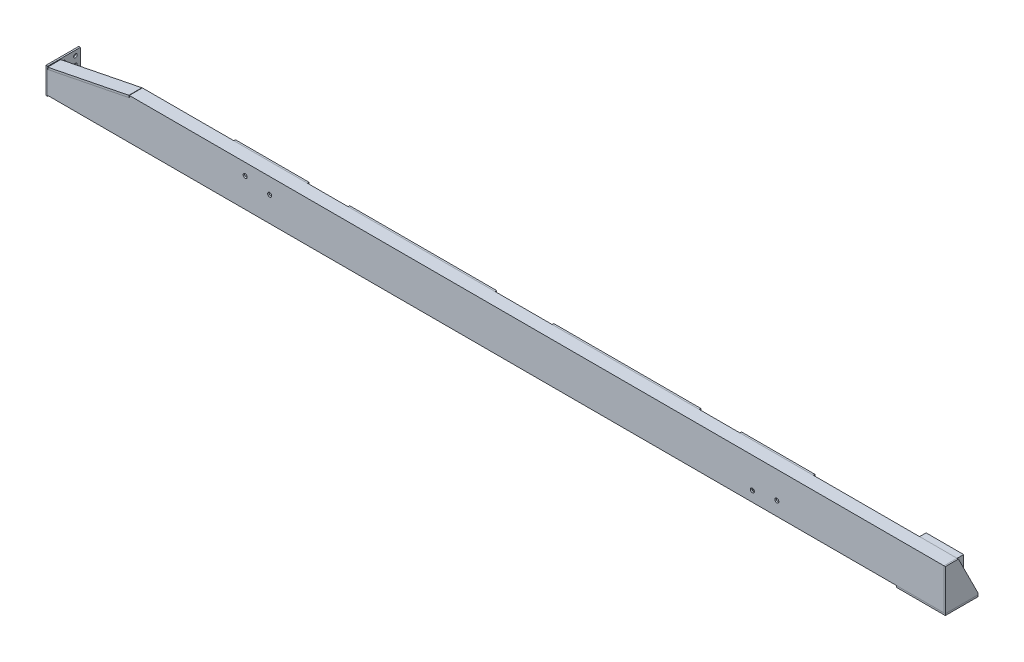
from build123d import *

# Parameters (mm, degrees)
MEMBER_25B_1_DEPTH       = 5490
CUT_EXTRUDE_START        = -80
CUT_EXTRUDE_1_DEPTH      = 80
EXTRUDE_1_DEPTH          = 80
FILLET_1_R               = 8
SKETCH_14_W              = 200
SKETCH_14_H              = 160
EXTRUDE_2_DEPTH          = 10
SKETCH_15_W              = 450
SKETCH_15_H              = 250
EXTRUDE_3_DEPTH          = 10
SKETCH_15_W_2            = 900
EXTRUDE_3_2_DEPTH        = 10
EXTRUDE_3_3_DEPTH        = 10
EXTRUDE_3_4_DEPTH        = 10
EXTRUDE_4_DEPTH          = 10
EXTRUDE_5_DEPTH          = 8
CUT_EXTRUDE_START_2      = -90
SKETCH_19_R              = 12.5
CUT_EXTRUDE_3_DEPTH      = 90
SKETCH_18_R              = 12.5
CUT_EXTRUDE_2_DEPTH      = 90
SKETCH_20_W              = 50
SKETCH_20_H              = 72
CUT_EXTRUDE_4_DEPTH      = 26.40959
SKETCH_21_W              = 180
SKETCH_21_H              = 72
CUT_EXTRUDE_5_DEPTH      = 26.409593
SKETCH_22_R              = 10.852040472
CUT_EXTRUDE_6_DEPTH      = 10
SKETCH_23_W              = 230
SKETCH_23_H              = 250
SKETCH_23_R              = 68
SKETCH_23_R_2            = 9.5
EXTRUDE_6_DEPTH          = 40
CUT_EXTRUDE_7_REACH      = 5281.716
CUT_EXTRUDE_7_END_RADIUS = 68
SKETCH_24_W              = 40
SKETCH_24_H              = 65
SKETCH_25_W              = 24
SKETCH_25_H              = 230
CUT_EXTRUDE_8_DEPTH      = 220
FILLET_2_R               = 20
FILLET_3_R               = 10
SKETCH_26_R              = 9
CUT_EXTRUDE_9_DEPTH      = 10
CUT_EXTRUDE_10_REACH     = 2775.481
SKETCH_26_2_R            = 9
CUT_EXTRUDE_11_REACH     = 2775.54
SKETCH_27_R              = 7
PATTERN_LINEAR_1_COUNT   = 2
PATTERN_LINEAR_1_PITCH   = 3460
SKETCH_28_R              = 5
CUT_EXTRUDE_12_DEPTH     = 26.409593
FILLET_4_R               = 5
SKETCH_29_R              = 5
CUT_EXTRUDE_13_DEPTH     = 26.409593


with BuildPart() as part:
    # 草图11 → Member 25B_1 (new body)
    with BuildSketch(Plane(origin=(-2745, 125, 0), x_dir=(0, 0, -1), z_dir=(1, 0, 0))):
        with BuildLine():
            Line((0, -125), (80, -125))
            Line((80, -125), (80, -121.979610687))
            ThreePointArc((80, -121.979610687), (78.448694362, -117.953555736), (74.596960509, -116.009381366))
            Line((74.596960509, -116.009381366), (19.806078982, -110.530866091))
            ThreePointArc((19.806078982, -110.530866091), (12.102611276, -106.642517351), (9, -98.590407448))
            Line((9, -98.590407448), (9, 98.590407448))
            ThreePointArc((9, 98.590407448), (12.102611276, 106.642517351), (19.806078982, 110.530866091))
            Line((19.806078982, 110.530866091), (74.596960509, 116.009381366))
            ThreePointArc((74.596960509, 116.009381366), (78.448694362, 117.953555736), (80, 121.979610687))
            Line((80, 121.979610687), (80, 125))
            Line((80, 125), (0, 125))
            Line((0, 125), (0, -125))
        make_face()
    extrude(amount=MEMBER_25B_1_DEPTH)

    # 草图12 → 切除-拉伸1 (cut)
    with BuildSketch(Plane.XY.offset(CUT_EXTRUDE_START)):
        Polygon((-2745, 250), (-2745, 137.762353167), (-2245, 237.762353167), (-2245, 250), align=None)
    extrude(amount=CUT_EXTRUDE_1_DEPTH, mode=Mode.SUBTRACT)


with BuildPart() as body_2:
    # 草图13 → 凸台-拉伸1 (new body)
    with BuildSketch(Plane.XY):
        Polygon((-2742.646606378, 138.233031892), (-2245, 237.762353167), (-2247.353393622, 249.529321276), (-2745, 150), align=None)
    extrude(amount=-EXTRUDE_1_DEPTH)

    # 圆角1
    fillet_1_edges = [body_2.edges().sort_by_distance(p)[0] for p in [
        (-2493.823303189, 187.99769253, -80),
    ]]
    fillet(fillet_1_edges, radius=FILLET_1_R)


with BuildPart() as body_3:
    # 草图14 → 凸台-拉伸2 (new body)
    with BuildSketch(Plane.ZY.offset(2745)):
        with Locations((-100, 75)):
            Rectangle(SKETCH_14_W, SKETCH_14_H)
    extrude(amount=EXTRUDE_2_DEPTH)

    # 草图22 → 切除-拉伸6 (cut)
    with BuildSketch(Plane.ZY.offset(2755)):
        with Locations((-30, 115)):
            Circle(SKETCH_22_R)
        with Locations((-30, 35)):
            Circle(SKETCH_22_R)
        with Locations((-100, 25)):
            Circle(SKETCH_22_R)
        with Locations((-100, 75)):
            Circle(SKETCH_22_R)
        with Locations((-100, 125)):
            Circle(SKETCH_22_R)
        with Locations((-170, 125)):
            Circle(SKETCH_22_R)
        with Locations((-170, 75)):
            Circle(SKETCH_22_R)
        with Locations((-170, 25)):
            Circle(SKETCH_22_R)
    extrude(amount=-CUT_EXTRUDE_6_DEPTH, mode=Mode.SUBTRACT)


with BuildPart() as body_4:
    # 草图15 → 凸台-拉伸3 (new body)
    with BuildSketch(Plane(origin=(0, 0, -80), x_dir=(-1, 0, 0), z_dir=(0, 0, -1))):
        with Locations((-1640, 125)):
            Rectangle(SKETCH_15_W, SKETCH_15_H)
    extrude(amount=EXTRUDE_3_DEPTH)


with BuildPart() as body_5:
    # 草图15 → Extrude 3 2 (new body)
    with BuildSketch(Plane(origin=(0, 0, -80), x_dir=(-1, 0, 0), z_dir=(0, 0, -1))):
        with Locations((-715, 125)):
            Rectangle(SKETCH_15_W_2, SKETCH_15_H)
    extrude(amount=EXTRUDE_3_2_DEPTH)


with BuildPart() as body_6:
    # 草图15 → Extrude 3 3 (new body)
    with BuildSketch(Plane(origin=(0, 0, -80), x_dir=(-1, 0, 0), z_dir=(0, 0, -1))):
        with Locations((535, 125)):
            Rectangle(SKETCH_15_W_2, SKETCH_15_H)
    extrude(amount=EXTRUDE_3_3_DEPTH)


with BuildPart() as body_7:
    # 草图15 → Extrude 3 4 (new body)
    with BuildSketch(Plane(origin=(0, 0, -80), x_dir=(-1, 0, 0), z_dir=(0, 0, -1))):
        with Locations((1460, 125)):
            Rectangle(SKETCH_15_W, SKETCH_15_H)
    extrude(amount=EXTRUDE_3_4_DEPTH)


with BuildPart() as body_8:
    # 草图16 → 凸台-拉伸4 (new body)
    with BuildSketch(Plane.XZ):
        Polygon((2753, 0), (2453, 0), (2453, -70), (2653, -200), (2753, -200), align=None)
    extrude(amount=EXTRUDE_4_DEPTH)

    # 草图26 → 切除-拉伸9 (cut)
    with BuildSketch(Plane(origin=(0, 0, -0.816275032), x_dir=(1, 0, 0), z_dir=(0, 1, 0))):
        with Locations(Location((2701, 39.183724968, 0), (0, 0, 270))):
            Circle(SKETCH_26_R)
        with Locations(Location((2601, 39.183724968, 0), (0, 0, 270))):
            Circle(SKETCH_26_R)
        with Locations(Location((2501, 39.183724968, 0), (0, 0, 270))):
            Circle(SKETCH_26_R)
        with Locations(Location((2601, 139.183724968, 0), (0, 0, 270))):
            Circle(SKETCH_26_R)
        with Locations(Location((2701, 139.183724968, 0), (0, 0, 270))):
            Circle(SKETCH_26_R)
    extrude(amount=-CUT_EXTRUDE_9_DEPTH, mode=Mode.SUBTRACT)


with BuildPart() as body_9:
    # 草图17 → 凸台-拉伸5 (new body)
    with BuildSketch(Plane(origin=(2745, 0, 0), x_dir=(0, 0, -1), z_dir=(1, 0, 0))):
        Polygon((0, 0), (200, 0), (200, 10), (80, 250), (0, 250), align=None)
    extrude(amount=EXTRUDE_5_DEPTH)


with BuildPart() as cut_extrude_3_tool:
    # 草图19 → 切除-拉伸3 (new body)
    with BuildSketch(Plane(origin=(0, 0, -90), x_dir=(-1, 0, 0), z_dir=(0, 0, -1)).offset(CUT_EXTRUDE_START_2)):
        with Locations(Location((1535, 178, 0), (0, 0, 90))):
            Circle(SKETCH_19_R)
        with Locations(Location((1385, 153, 0), (0, 0, 90))):
            Circle(SKETCH_19_R)
    extrude(amount=CUT_EXTRUDE_3_DEPTH)


with BuildPart() as part_1:
    add(part.part)

    # 切除-拉伸3: cut by cut_extrude_3_tool
    add(cut_extrude_3_tool.part, mode=Mode.SUBTRACT)


with BuildPart() as body_7_1:
    add(body_7.part)

    # 切除-拉伸3: cut by cut_extrude_3_tool
    add(cut_extrude_3_tool.part, mode=Mode.SUBTRACT)


with BuildPart() as cut_extrude_2_tool:
    # 草图18 → 切除-拉伸2 (new body)
    with BuildSketch(Plane(origin=(0, 0, -90), x_dir=(-1, 0, 0), z_dir=(0, 0, -1)).offset(CUT_EXTRUDE_START_2)):
        with Locations(Location((-1721, 84, 0), (0, 0, 90))):
            Circle(SKETCH_18_R)
        with Locations(Location((-1571, 63, 0), (0, 0, 90))):
            Circle(SKETCH_18_R)
    extrude(amount=CUT_EXTRUDE_2_DEPTH)


with BuildPart() as part_2:
    add(part_1.part)

    # 切除-拉伸2: cut by cut_extrude_2_tool
    add(cut_extrude_2_tool.part, mode=Mode.SUBTRACT)

    # 草图20 → 切除-拉伸4 (cut)
    with BuildSketch(Plane.XZ):
        with Locations((-1587, -44)):
            Rectangle(SKETCH_20_W, SKETCH_20_H)
    extrude(amount=-CUT_EXTRUDE_4_DEPTH, mode=Mode.SUBTRACT)

    # 草图21 → 切除-拉伸5 (cut)
    with BuildSketch(Plane.XZ):
        with Locations((1606, -44)):
            Rectangle(SKETCH_21_W, SKETCH_21_H)
    extrude(amount=-CUT_EXTRUDE_5_DEPTH, mode=Mode.SUBTRACT)

    # 切除-拉伸10: up to this plane
    cut_extrude_10_end = Plane(origin=(2745, 8.990618634, -74.596960509), z_dir=(0, -0.9950382202393004, 0.09949341818937339))
    # 草图26<2> → 切除-拉伸10 (cut, up to the surface)
    with BuildSketch(Plane(origin=(0, 0, -0.816275032), x_dir=(1, 0, 0), z_dir=(0, 1, 0)), mode=Mode.PRIVATE) as cut_extrude_10_sk1:
        with Locations(Location((2701, 39.183724968, 0), (0, 0, 270))):
            Circle(SKETCH_26_2_R)
    cut_extrude_10_tool1 = split(extrude(cut_extrude_10_sk1.sketch, amount=CUT_EXTRUDE_10_REACH, mode=Mode.PRIVATE), bisect_by=cut_extrude_10_end, keep=Keep.BOTH, mode=Mode.PRIVATE)
    add(cut_extrude_10_tool1.solids().sort_by_distance((2701, 0, -40))[0], mode=Mode.SUBTRACT)
    # 草图26<2> → 切除-拉伸10 (cut, up to the surface)
    with BuildSketch(Plane(origin=(0, 0, -0.816275032), x_dir=(1, 0, 0), z_dir=(0, 1, 0)), mode=Mode.PRIVATE) as cut_extrude_10_sk2:
        with Locations(Location((2601, 39.183724968, 0), (0, 0, 270))):
            Circle(SKETCH_26_2_R)
    cut_extrude_10_tool2 = split(extrude(cut_extrude_10_sk2.sketch, amount=CUT_EXTRUDE_10_REACH, mode=Mode.PRIVATE), bisect_by=cut_extrude_10_end, keep=Keep.BOTH, mode=Mode.PRIVATE)
    add(cut_extrude_10_tool2.solids().sort_by_distance((2601, 0, -40))[0], mode=Mode.SUBTRACT)
    # 草图26<2> → 切除-拉伸10 (cut, up to the surface)
    with BuildSketch(Plane(origin=(0, 0, -0.816275032), x_dir=(1, 0, 0), z_dir=(0, 1, 0)), mode=Mode.PRIVATE) as cut_extrude_10_sk3:
        with Locations(Location((2501, 39.183724968, 0), (0, 0, 270))):
            Circle(SKETCH_26_2_R)
    cut_extrude_10_tool3 = split(extrude(cut_extrude_10_sk3.sketch, amount=CUT_EXTRUDE_10_REACH, mode=Mode.PRIVATE), bisect_by=cut_extrude_10_end, keep=Keep.BOTH, mode=Mode.PRIVATE)
    add(cut_extrude_10_tool3.solids().sort_by_distance((2501, 0, -40))[0], mode=Mode.SUBTRACT)
    # 草图26<2> → 切除-拉伸10 (cut, up to the surface)
    with BuildSketch(Plane(origin=(0, 0, -0.816275032), x_dir=(1, 0, 0), z_dir=(0, 1, 0)), mode=Mode.PRIVATE) as cut_extrude_10_sk4:
        with Locations(Location((2601, 139.183724968, 0), (0, 0, 270))):
            Circle(SKETCH_26_2_R)
    cut_extrude_10_tool4 = split(extrude(cut_extrude_10_sk4.sketch, amount=CUT_EXTRUDE_10_REACH, mode=Mode.PRIVATE), bisect_by=cut_extrude_10_end, keep=Keep.BOTH, mode=Mode.PRIVATE)
    add(cut_extrude_10_tool4.solids().sort_by_distance((2601, 0, -140))[0], mode=Mode.SUBTRACT)
    # 草图26<2> → 切除-拉伸10 (cut, up to the surface)
    with BuildSketch(Plane(origin=(0, 0, -0.816275032), x_dir=(1, 0, 0), z_dir=(0, 1, 0)), mode=Mode.PRIVATE) as cut_extrude_10_sk5:
        with Locations(Location((2701, 139.183724968, 0), (0, 0, 270))):
            Circle(SKETCH_26_2_R)
    cut_extrude_10_tool5 = split(extrude(cut_extrude_10_sk5.sketch, amount=CUT_EXTRUDE_10_REACH, mode=Mode.PRIVATE), bisect_by=cut_extrude_10_end, keep=Keep.BOTH, mode=Mode.PRIVATE)
    add(cut_extrude_10_tool5.solids().sort_by_distance((2701, 0, -140))[0], mode=Mode.SUBTRACT)

    # 切除-拉伸11: up to this plane
    cut_extrude_11_end = Plane(origin=(2745, 8.990618634, -74.596960509), z_dir=(0, -0.9950382202393004, 0.09949341818937339))
    # 草图27 → 切除-拉伸11 (cut, up to the surface)
    with BuildSketch(Plane.XZ, mode=Mode.PRIVATE) as cut_extrude_11_sk1:
        with Locations(Location((1799, -30, 0), (0, 0, 270))):
            Circle(SKETCH_27_R)
    cut_extrude_11_tool1 = split(extrude(cut_extrude_11_sk1.sketch, amount=-CUT_EXTRUDE_11_REACH, mode=Mode.PRIVATE), bisect_by=cut_extrude_11_end, keep=Keep.BOTH, mode=Mode.PRIVATE)
    # 草图27 → 切除-拉伸11 (cut, up to the surface)
    with BuildSketch(Plane.XZ, mode=Mode.PRIVATE) as cut_extrude_11_sk2:
        with Locations(Location((1713, -30, 0), (0, 0, 270))):
            Circle(SKETCH_27_R)
    cut_extrude_11_tool2 = split(extrude(cut_extrude_11_sk2.sketch, amount=-CUT_EXTRUDE_11_REACH, mode=Mode.PRIVATE), bisect_by=cut_extrude_11_end, keep=Keep.BOTH, mode=Mode.PRIVATE)
    cut_extrude_11 = cut_extrude_11_tool1.solids().sort_by_distance((1799, 0, -30))[0] + cut_extrude_11_tool2.solids().sort_by_distance((1713, 0, -30))[0]
    add(cut_extrude_11, mode=Mode.SUBTRACT)

    # 阵列(线性)1: 切除-拉伸11 ×2
    with Locations(*[(-i * PATTERN_LINEAR_1_PITCH, 0, 0) for i in range(1, PATTERN_LINEAR_1_COUNT)]):
        add(cut_extrude_11, mode=Mode.SUBTRACT)

    # 草图28 → 切除-拉伸12 (cut)
    with BuildSketch(Plane.XZ):
        with Locations(Location((1316, -15, 0), (0, 0, 270))):
            Circle(SKETCH_28_R)
        with Locations(Location((1416, -15, 0), (0, 0, 270))):
            Circle(SKETCH_28_R)
        with Locations(Location((1316, -65, 0), (0, 0, 270))):
            Circle(SKETCH_28_R)
        with Locations(Location((1416, -65, 0), (0, 0, 270))):
            Circle(SKETCH_28_R)
    extrude(amount=-CUT_EXTRUDE_12_DEPTH, mode=Mode.SUBTRACT)

    # 草图29 → 切除-拉伸13 (cut)
    with BuildSketch(Plane.XZ):
        with Locations(Location((-1380, -65, 0), (0, 0, 270))):
            Circle(SKETCH_29_R)
        with Locations(Location((-1380, -15, 0), (0, 0, 270))):
            Circle(SKETCH_29_R)
        with Locations(Location((-1280, -15, 0), (0, 0, 270))):
            Circle(SKETCH_29_R)
        with Locations(Location((-1280, -65, 0), (0, 0, 270))):
            Circle(SKETCH_29_R)
    extrude(amount=-CUT_EXTRUDE_13_DEPTH, mode=Mode.SUBTRACT)


with BuildPart() as body_4_1:
    add(body_4.part)

    # 切除-拉伸2: cut by cut_extrude_2_tool
    add(cut_extrude_2_tool.part, mode=Mode.SUBTRACT)


with BuildPart() as body_10:
    # 草图23 → 凸台-拉伸6 (new body)
    with BuildSketch(Plane(origin=(0, 0, -80), x_dir=(-1, 0, 0), z_dir=(0, 0, -1))):
        with Locations((-2630, 125)):
            Rectangle(SKETCH_23_W, SKETCH_23_H)
        with Locations(Location((-2610, 129, 0), (0, 0, 90))):
            Circle(SKETCH_23_R, mode=Mode.SUBTRACT)
        with Locations(Location((-2666.568542495, 185.568542495, 0), (0, 0, 90))):
            Circle(SKETCH_23_R_2, mode=Mode.SUBTRACT)
        with Locations(Location((-2553.431457505, 185.568542495, 0), (0, 0, 90))):
            Circle(SKETCH_23_R_2, mode=Mode.SUBTRACT)
        with Locations(Location((-2553.431457505, 72.431457505, 0), (0, 0, 90))):
            Circle(SKETCH_23_R_2, mode=Mode.SUBTRACT)
        with Locations(Location((-2666.568542495, 72.431457505, 0), (0, 0, 90))):
            Circle(SKETCH_23_R_2, mode=Mode.SUBTRACT)
    extrude(amount=EXTRUDE_6_DEPTH)

    # 切除-拉伸7: up to this cylinder (the profile starts outside it)
    cut_extrude_7_end = Plane(origin=(2610, 129, -100), z_dir=(0, 0, 1)) * Cylinder(CUT_EXTRUDE_7_END_RADIUS, 10700.432, mode=Mode.PRIVATE)
    # 草图24 → 切除-拉伸7 (cut, up to the surface)
    with BuildSketch(Plane.ZY.offset(-2515), mode=Mode.PRIVATE) as cut_extrude_7_sk1:
        with Locations((-100, 138)):
            Rectangle(SKETCH_24_W, SKETCH_24_H)
    cut_extrude_7_tool1 = extrude(cut_extrude_7_sk1.sketch, amount=-CUT_EXTRUDE_7_REACH, mode=Mode.PRIVATE) - cut_extrude_7_end
    add(cut_extrude_7_tool1.solids().sort_by_distance((2515, 138, -100))[0], mode=Mode.SUBTRACT)

    # 草图25 → 切除-拉伸8 (cut)
    with BuildSketch(Plane.ZY.offset(-2515)):
        with Locations((-92, 125)):
            Rectangle(SKETCH_25_W, SKETCH_25_H)
    extrude(amount=-CUT_EXTRUDE_8_DEPTH, mode=Mode.SUBTRACT)

    # 圆角2
    fillet_2_edges = [body_10.edges().sort_by_distance(p)[0] for p in [
        (2735, 10, -92),
        (2735, 240, -92),
    ]]
    fillet(fillet_2_edges, radius=FILLET_2_R)

    # 圆角3
    fillet_3_edges = [body_10.edges().sort_by_distance(p)[0] for p in [
        (2515, 105.5, -112),
        (2515, 170.5, -112),
    ]]
    fillet(fillet_3_edges, radius=FILLET_3_R)

    # 圆角4
    fillet_4_edges = [body_10.edges().sort_by_distance(p)[0] for p in [
        (2735, 125, -104),
        (2615, 10, -104),
        (2615, 240, -104),
        (2729.142135624, 234.142135624, -104),
        (2729.142135624, 15.857864376, -104),
    ]]
    fillet(fillet_4_edges, radius=FILLET_4_R)


solid = Compound([body_2.part, body_3.part, body_5.part, body_6.part, body_8.part, body_9.part, body_7_1.part, part_2.part, body_4_1.part, body_10.part])
